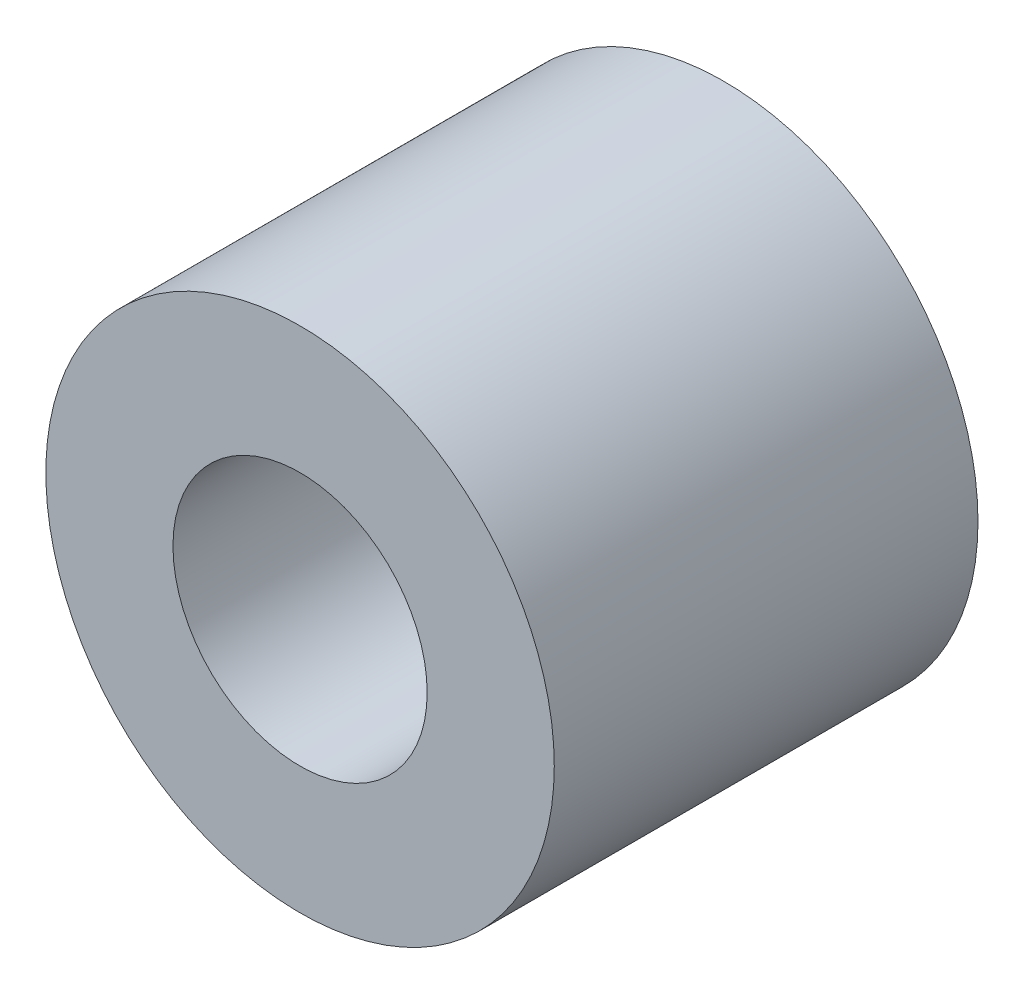
from build123d import *

# Parameters (mm, degrees)
SKETCH1_R           = 30
SKETCH1_R_2         = 15
BOSS_EXTRUDE1_DEPTH = 25


with BuildPart() as part:
    # Sketch1 → Boss-Extrude1 (new body, symmetric)
    with BuildSketch(Plane.XY):
        Circle(SKETCH1_R)
        Circle(SKETCH1_R_2, mode=Mode.SUBTRACT)
    extrude(amount=BOSS_EXTRUDE1_DEPTH, both=True)


solid = part.part
